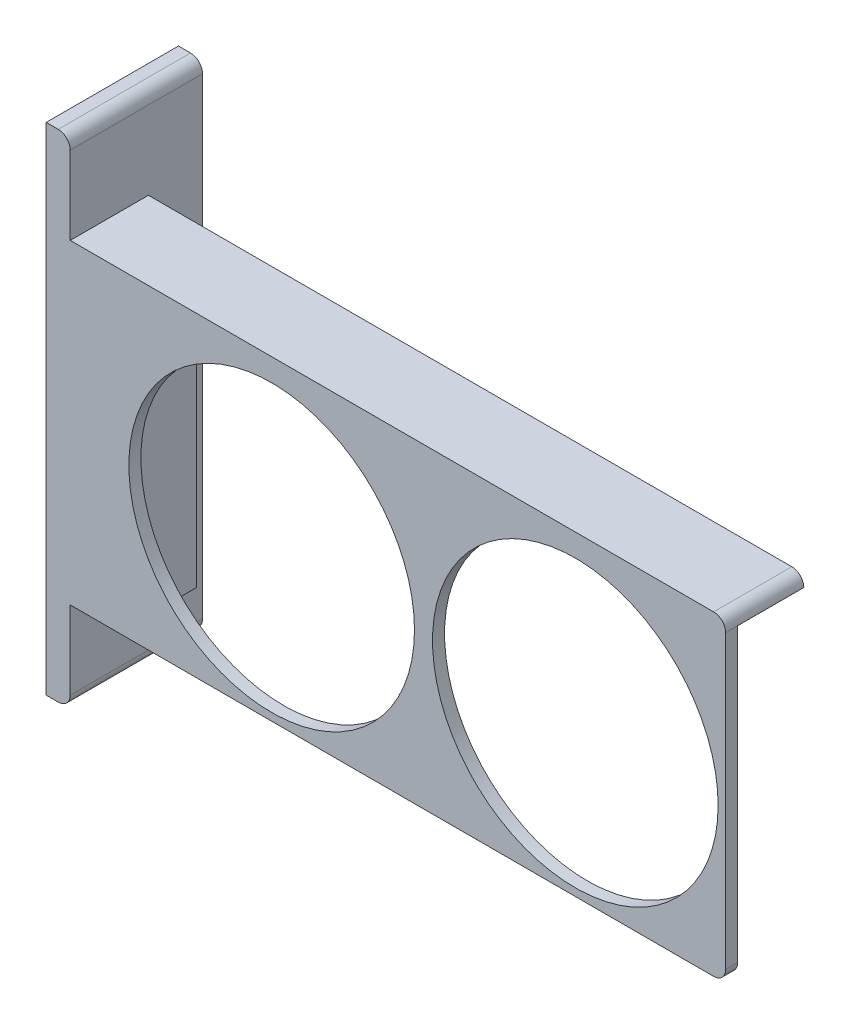
from build123d import *

# Parameters (mm, degrees)
SKETCH_1_W           = 113
SKETCH_1_H           = 52.5
SKETCH_1_R           = 23.75
EXTRUDE_1_DEPTH      = 2
SKETCH_2_W           = 113
SKETCH_2_H           = 2
EXTRUDE_2_DEPTH      = 11
FILLET_1_R           = 2
SKETCH_3_W           = 4
SKETCH_3_H           = 52.5
EXTRUDE_3_DEPTH      = 20
EXTRUDE_4_DEPTH      = 11
SKETCH_5_W           = 4
SKETCH_5_H           = 22
EXTRUDE_5_DEPTH      = 15
EXTRUDE_5_DEPTH_BACK = 67.5
FILLET_2_R           = 2


with BuildPart() as part:
    # 스케치1 → 보스-돌출1 (new body)
    with BuildSketch(Plane.XY):
        with Locations((56.5, 26.25)):
            Rectangle(SKETCH_1_W, SKETCH_1_H)
        with Locations((88, 25)):
            Circle(SKETCH_1_R, mode=Mode.SUBTRACT)
        with Locations((37.5, 25)):
            Circle(SKETCH_1_R, mode=Mode.SUBTRACT)
    extrude(amount=EXTRUDE_1_DEPTH)

    # 스케치2 → 보스-돌출2 (add)
    with BuildSketch(Plane(origin=(0, 0, 0), x_dir=(-1, 0, 0), z_dir=(0, 0, -1))):
        with Locations((-56.5, 51.5)):
            Rectangle(SKETCH_2_W, SKETCH_2_H)
    extrude(amount=EXTRUDE_2_DEPTH)

    # 필렛1
    fillet_1_edges = [part.edges().sort_by_distance(p)[0] for p in [
        (113, 0, 1),
        (113, 52.5, -4.5),
    ]]
    fillet(fillet_1_edges, radius=FILLET_1_R)

    # 스케치3 → 보스-돌출3 (add)
    with BuildSketch(Plane(origin=(0, 0, 0), x_dir=(-1, 0, 0), z_dir=(0, 0, -1))):
        with Locations((-2, 26.25)):
            Rectangle(SKETCH_3_W, SKETCH_3_H)
    extrude(amount=EXTRUDE_3_DEPTH)

    # 스케치4 → 보스-돌출4 (add)
    with BuildSketch(Plane(origin=(0, 0, 0), x_dir=(-1, 0, 0), z_dir=(0, 0, -1))):
        Polygon((-4, 0), (-4, 50.5), (-12, 50.5), (-12, 25), (-12, 0), align=None)
    extrude(amount=EXTRUDE_4_DEPTH)

    # 스케치5 → 보스-돌출5 (add, two sides)
    with BuildSketch(Plane(origin=(0, 52.5, 0), x_dir=(1, 0, 0), z_dir=(0, 1, 0))) as extrude_5_sk:
        with Locations((2, 9)):
            Rectangle(SKETCH_5_W, SKETCH_5_H)
    extrude(amount=EXTRUDE_5_DEPTH)
    extrude(extrude_5_sk.sketch, amount=-EXTRUDE_5_DEPTH_BACK)

    # 필렛2
    fillet_2_edges = [part.edges().sort_by_distance(p)[0] for p in [
        (4, -15, -9),
        (4, 67.5, -9),
    ]]
    fillet(fillet_2_edges, radius=FILLET_2_R)


solid = part.part
